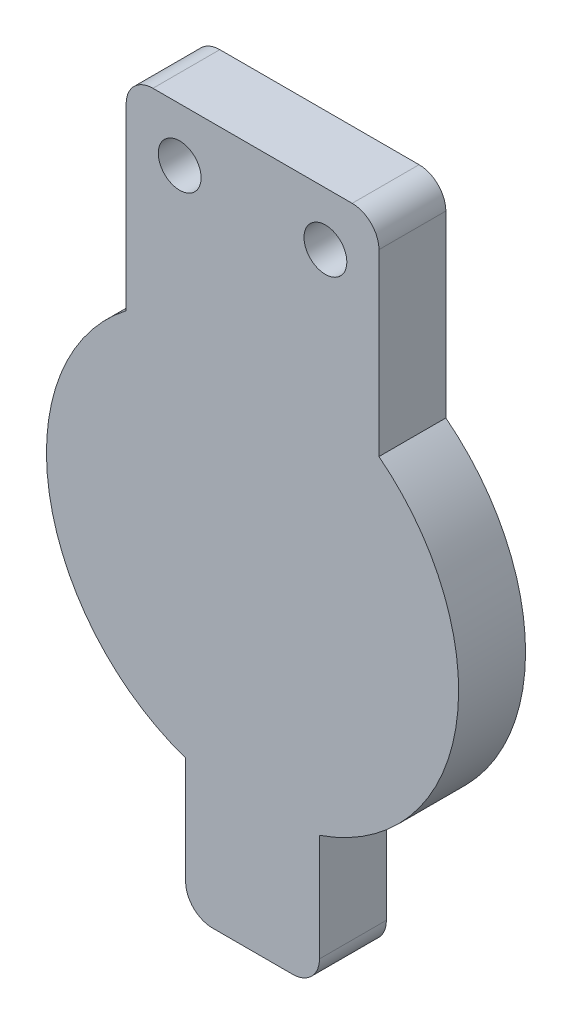
from build123d import *

# Parameters (mm, degrees)
SKETCH1_R           = 2.032
BOSS_EXTRUDE1_DEPTH = 6.35
FILLET1_R           = 2.54


with BuildPart() as part:
    # Sketch1 → Boss-Extrude1 (new body)
    with BuildSketch(Plane.XY):
        with BuildLine():
            ThreePointArc((6.35, -18.498455719), (0, -19.558), (-6.35, -18.498455719))
            Line((-6.35, -18.498455719), (-6.35, -31.198455719))
            Line((-6.35, -31.198455719), (6.35, -31.198455719))
            Line((6.35, -31.198455719), (6.35, -18.498455719))
        make_face()
        with BuildLine():
            Line((-11.994797213, 34.995050133), (-11.994797213, 15.447983811))
            ThreePointArc((-11.994797213, 15.447983811), (-19.293083875, -3.208158134), (-6.35, -18.498455719))
            Line((-6.35, -18.498455719), (6.35, -18.498455719))
            ThreePointArc((6.35, -18.498455719), (19.293083875, -3.208158134), (11.994797213, 15.447983811))
            Line((11.994797213, 15.447983811), (11.994797213, 34.995050133))
            Line((11.994797213, 34.995050133), (-11.994797213, 34.995050133))
        make_face()
        with Locations((-6.914797213, 29.915050133)):
            Circle(SKETCH1_R, mode=Mode.SUBTRACT)
        with Locations((6.914797213, 29.915050133)):
            Circle(SKETCH1_R, mode=Mode.SUBTRACT)
        with BuildLine():
            Line((6.35, -18.498455719), (-6.35, -18.498455719))
            ThreePointArc((-6.35, -18.498455719), (0, -19.558), (6.35, -18.498455719))
        make_face()
    extrude(amount=BOSS_EXTRUDE1_DEPTH)

    # Fillet1
    fillet1_edges = [part.edges().sort_by_distance(p)[0] for p in [
        (6.35, -31.198455719, 3.175),
        (-6.35, -31.198455719, 3.175),
        (11.994797213, 34.995050133, 3.175),
        (-11.994797213, 34.995050133, 3.175),
    ]]
    fillet(fillet1_edges, radius=FILLET1_R)


solid = part.part
